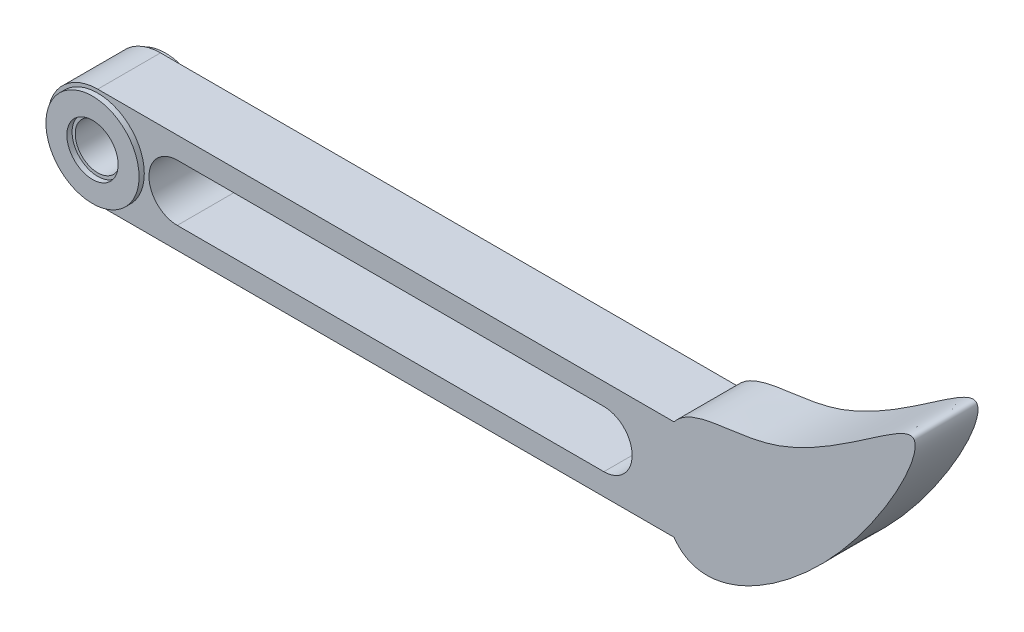
from build123d import *

# Parameters (mm, degrees)
EXTRUDE_1_DEPTH          = 3
SKETCH_2_R               = 2.15
CUT_EXTRUDE_2_DEPTH      = 10
CUT_EXTRUDE_2_DEPTH_BACK = 1
SKETCH_6_R               = 4.45
SKETCH_6_R_2             = 2.45
EXTRUDE_1_2_DEPTH        = 0.5
SKETCH_7_R               = 4.5
SKETCH_7_R_2             = 2.5
EXTRUDE_2_DEPTH          = 0.5
CUT_EXTRUDE_3_DEPTH      = 10
EXTRUDE_2_2_DEPTH        = 6


with BuildPart() as part:
    # 草图1 → Extrude 1 (new body, symmetric)
    with BuildSketch(Plane.XY):
        with BuildLine():
            Line((25.056911311, -4.773033008), (-34.943088689, -4.773033008))
            ThreePointArc((-34.943088689, -4.773033008), (-39.716121697, 0), (-34.943088689, 4.773033008))
            Line((-34.943088689, 4.773033008), (25.056911311, 4.773033008))
            Line((25.056911311, 4.773033008), (25.056911311, -4.773033008))
        make_face()
    extrude(amount=EXTRUDE_1_DEPTH, both=True)

    # 草图2 → 切除-拉伸2 (cut, two sides)
    with BuildSketch(Plane(origin=(0, -0.226966992, -3), x_dir=(1, 0, 0), z_dir=(0, 0, 1))) as cut_extrude_2_sk:
        with Locations((-30, 0.226966992)):
            Circle(SKETCH_2_R)
        with BuildLine():
            Line((-22.401694851, 2.926966992), (18.356911311, 2.926966992))
            ThreePointArc((18.356911311, 2.926966992), (21.056911311, 0.226966992), (18.356911311, -2.473033008))
            Line((18.356911311, -2.473033008), (-22.401694851, -2.473033008))
            ThreePointArc((-22.401694851, -2.473033008), (-25.101694851, 0.226966992), (-22.401694851, 2.926966992))
        make_face()
    extrude(amount=CUT_EXTRUDE_2_DEPTH, mode=Mode.SUBTRACT)
    extrude(cut_extrude_2_sk.sketch, amount=-CUT_EXTRUDE_2_DEPTH_BACK, mode=Mode.SUBTRACT)

    # 草图6 → Extrude 1 2 (add)
    with BuildSketch(Plane.XY.offset(3)):
        with Locations((-30, 0)):
            Circle(SKETCH_6_R)
        with Locations((-30, 0)):
            Circle(SKETCH_6_R_2, mode=Mode.SUBTRACT)
    extrude(amount=EXTRUDE_1_2_DEPTH)

    # 草图7 → Extrude 2 (add)
    with BuildSketch(Plane(origin=(0, 0, -3), x_dir=(-1, 0, 0), z_dir=(0, 0, -1))):
        with Locations((30, 0)):
            Circle(SKETCH_7_R)
        with Locations((30, 0)):
            Circle(SKETCH_7_R_2, mode=Mode.SUBTRACT)
    extrude(amount=EXTRUDE_2_DEPTH)

    # 草图9 → 切除-拉伸3 (cut)
    with BuildSketch(Plane.XY.offset(3)):
        with BuildLine():
            Line((-30, 4.773033008), (-45.254919606, 4.773033008))
            Line((-45.254919606, 4.773033008), (-45.254919606, -4.773033008))
            Line((-45.254919606, -4.773033008), (-30, -4.773033008))
            ThreePointArc((-30, -4.773033008), (-34.773033008, 0), (-30, 4.773033008))
        make_face()
    extrude(amount=-CUT_EXTRUDE_3_DEPTH, mode=Mode.SUBTRACT)

    # 草图11 → Extrude 2 2 (add)
    with BuildSketch(Plane.XY.offset(3)):
        with BuildLine():
            add(Edge.make_bspline(
                [(25.056911311, -4.773033008), (27.815239946, -8.737333347), (41.585070211, -0.864093582), (52.804357996, 21.672077098), (36.415875516, 5.496268281), (23.158409155, 7.58630405), (23.452448802, -2.467081791), (25.056911311, -4.773033008)],
                knots=[0, 0, 0, 0, 0.246515534, 0.480336102, 0.712513076, 0.856607031, 1, 1, 1, 1], degree=3))
        make_face()
    extrude(amount=-EXTRUDE_2_2_DEPTH)


solid = part.part
